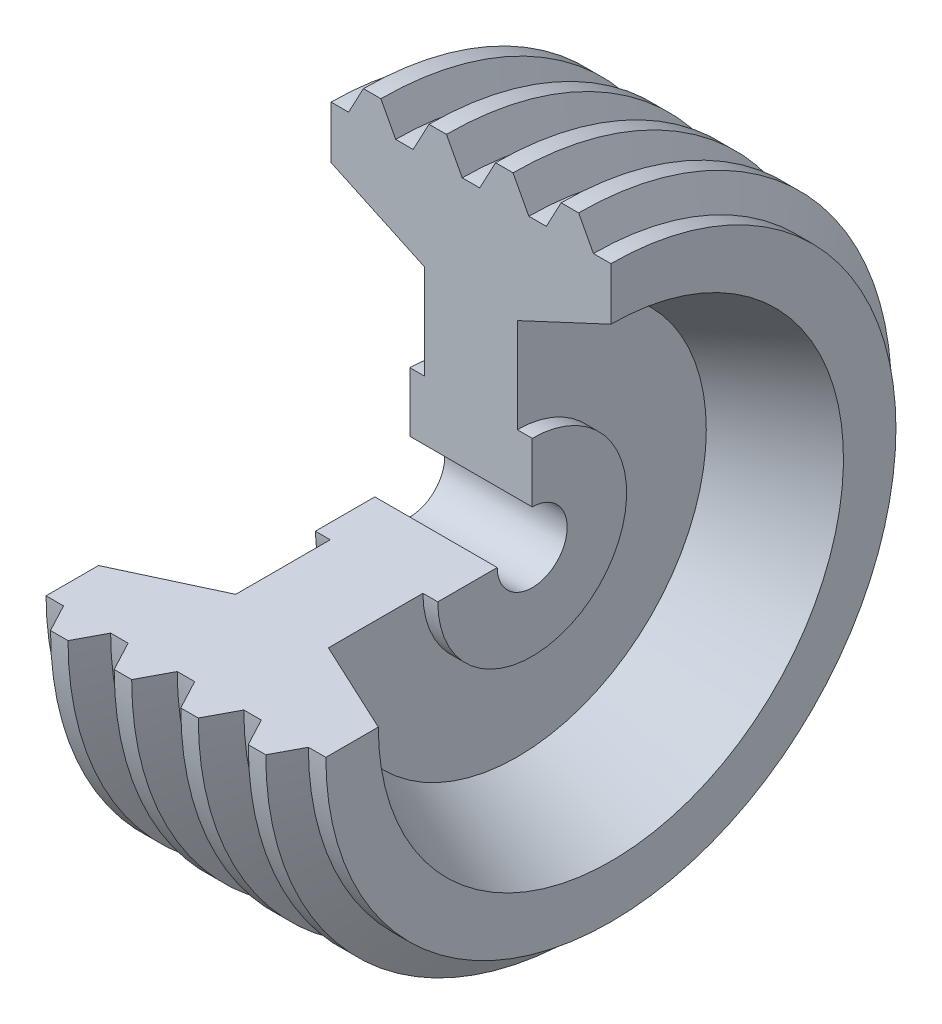
from build123d import *

# Parameters (mm, degrees)
REVOLVE1_ANGLE = 270


with BuildPart() as part:
    # Sketch1 → Revolve1 (revolve)
    with BuildSketch(Plane.XY):
        Polygon((-889, 508), (889, 508), (889, 1371.6), (673.1, 1371.6), (673.1, 2744.534523333), (2032, 3378.2), (2032, 4140.2), (1778, 4140.2), (1563.092132591, 4544.382913846), (1309.092132591, 4544.382913846), (1094.184265183, 4140.2), (840.184265183, 4140.2), (610.592132591, 4572), (356.592132591, 4572), (127, 4140.2), (-127, 4140.2), (-356.592132591, 4572), (-610.592132591, 4572), (-840.184265183, 4140.2), (-1094.184265183, 4140.2), (-1309.092132591, 4544.382913846), (-1563.092132591, 4544.382913846), (-1778, 4140.2), (-2032, 4140.2), (-2032, 3378.2), (-673.1, 2744.534523333), (-673.1, 1371.6), (-889, 1371.6), align=None)
    revolve(axis=Axis((-2111.121296774, 0, 0), (-1, 0, 0)), revolution_arc=REVOLVE1_ANGLE)


solid = part.part
